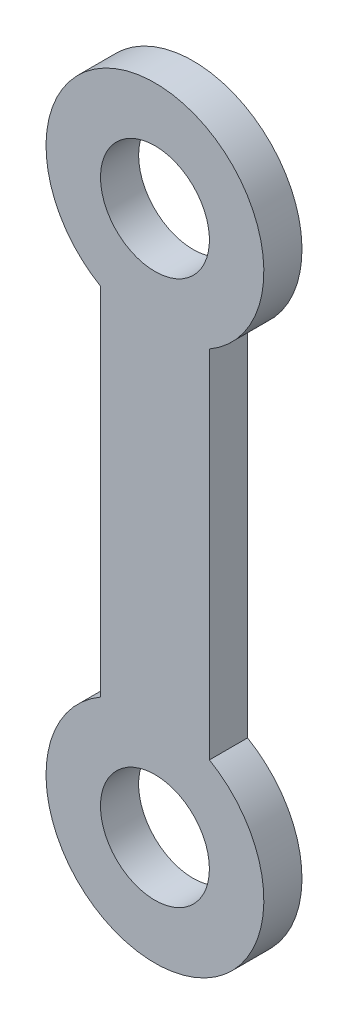
from build123d import *

# Parameters (mm, degrees)
SKETCH1_R           = 2
BOSS_EXTRUDE1_DEPTH = 1.4


with BuildPart() as part:
    # Sketch1 → Boss-Extrude1 (new body)
    with BuildSketch(Plane.XY):
        with BuildLine():
            Line((-2, 16.535898385), (-2, 3.464101615))
            ThreePointArc((-2, 3.464101615), (0, -4), (2, 3.464101615))
            Line((2, 3.464101615), (2, 16.535898385))
            ThreePointArc((2, 16.535898385), (0, 24), (-2, 16.535898385))
        make_face()
        Circle(SKETCH1_R, mode=Mode.SUBTRACT)
        with Locations((0, 20)):
            Circle(SKETCH1_R, mode=Mode.SUBTRACT)
    extrude(amount=BOSS_EXTRUDE1_DEPTH)


solid = part.part
